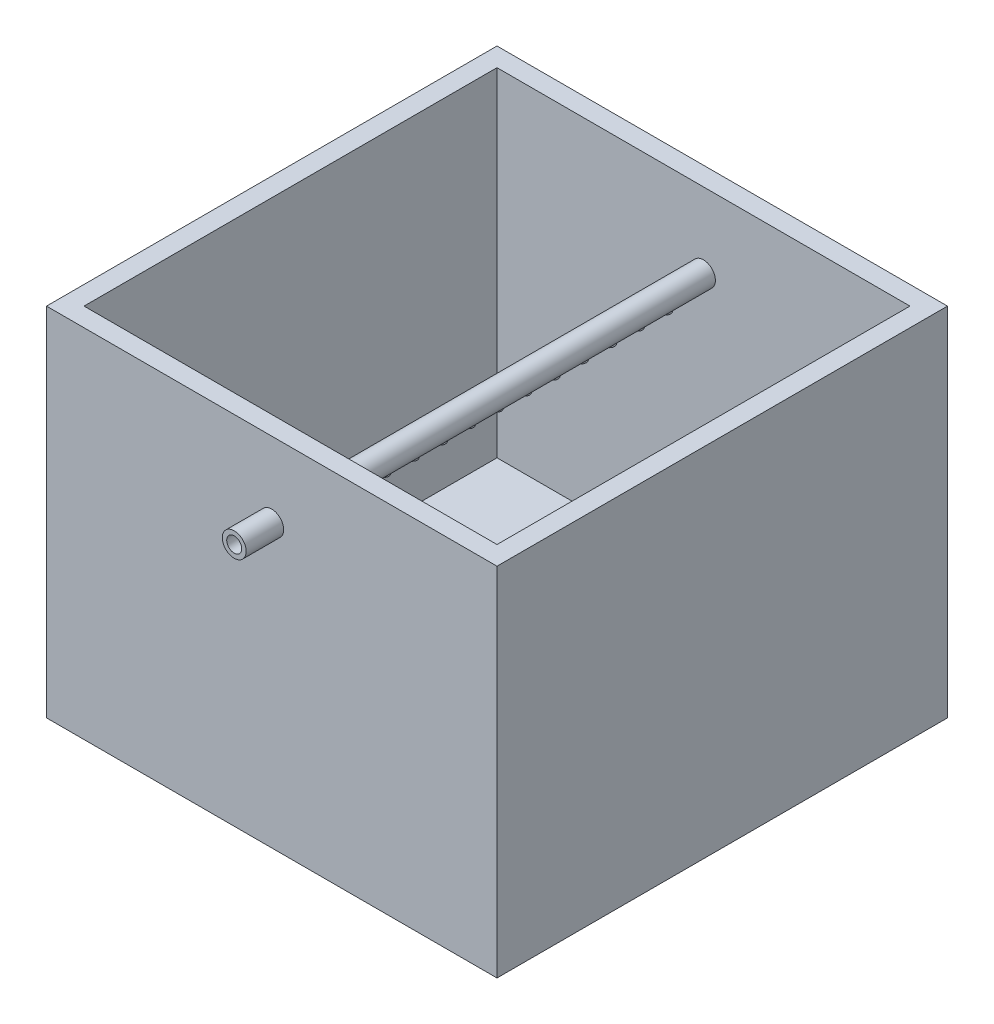
from build123d import *

# Parameters (mm, degrees)
SKETCH1_W                = 120
SKETCH1_H                = 120
BOSS_EXTRUDE1_DEPTH      = 150
SHELL1_T                 = -5
SKETCH2_R                = 3.175
SKETCH2_R_2              = 2
BOSS_EXTRUDE2_DEPTH      = 10
BOSS_EXTRUDE2_DEPTH_BACK = 116
SKETCH3_R                = 1
CUT_EXTRUDE1_DEPTH       = 70
SKETCH4_W                = 120
SKETCH4_H                = 67.243067728
CUT_EXTRUDE2_DEPTH       = 120
SKETCH5_R                = 3.175
SKETCH5_R_2              = 2
BOSS_EXTRUDE3_DEPTH      = 10
SKETCH6_R                = 2
CUT_EXTRUDE3_DEPTH       = 10
SKETCH7_R                = 2
CUT_EXTRUDE4_DEPTH       = 29
SKETCH10_R               = 1.274958532
SKETCH10_R_2             = 1
SKETCH10_R_3             = 1.234995547
SKETCH10_R_4             = 1.322689939
SKETCH10_R_5             = 1.286317059
SKETCH10_R_6             = 1.294952296
SKETCH10_R_7             = 1.196319739
SKETCH10_R_8             = 1.153199308
SKETCH10_R_9             = 1.2271988
SKETCH10_R_10            = 1.254103204
SKETCH10_R_11            = 1.23593489
SKETCH10_R_12            = 1.183992993
SKETCH10_R_13            = 1.194935368
SKETCH10_R_14            = 1.244247118
BOSS_EXTRUDE4_DEPTH      = 0.5
BOSS_EXTRUDE4_DEPTH_BACK = 1


with BuildPart() as part:
    # Sketch1 → Boss-Extrude1 (new body)
    with BuildSketch(Plane(origin=(0, 0, 0), x_dir=(1, 0, 0), z_dir=(0, 1, 0))):
        Rectangle(SKETCH1_W, SKETCH1_H)
    extrude(amount=BOSS_EXTRUDE1_DEPTH)

    # Shell1
    shell1_openings = [part.faces().sort_by_distance(p)[0] for p in [
        (0, 150, 0),
    ]]
    offset(amount=SHELL1_T, openings=shell1_openings, kind=Kind.INTERSECTION)

    # Sketch2 → Boss-Extrude2 (add, two sides)
    with BuildSketch(Plane.XY.offset(60)) as boss_extrude2_sk:
        with Locations((0, 75)):
            Circle(SKETCH2_R)
        with Locations((0, 75)):
            Circle(SKETCH2_R_2, mode=Mode.SUBTRACT)
    extrude(amount=BOSS_EXTRUDE2_DEPTH)
    extrude(boss_extrude2_sk.sketch, amount=-BOSS_EXTRUDE2_DEPTH_BACK)

    # Sketch3 → Cut-Extrude1 (cut)
    with BuildSketch(Plane(origin=(0, 5, 0), x_dir=(1, 0, 0), z_dir=(0, 1, 0))):
        Circle(SKETCH3_R)
        with Locations((0, 7.5)):
            Circle(SKETCH3_R)
        with Locations((0, -7.5)):
            Circle(SKETCH3_R)
        with Locations((0, -15)):
            Circle(SKETCH3_R)
        with Locations((0, 15)):
            Circle(SKETCH3_R)
        with Locations((0, -22.5)):
            Circle(SKETCH3_R)
        with Locations((0, 22.5)):
            Circle(SKETCH3_R)
        with Locations((0, -30)):
            Circle(SKETCH3_R)
        with Locations((0, 30)):
            Circle(SKETCH3_R)
        with Locations((0, -37.5)):
            Circle(SKETCH3_R)
        with Locations((0, 37.5)):
            Circle(SKETCH3_R)
        with Locations((0, -45)):
            Circle(SKETCH3_R)
        with Locations((0, 45)):
            Circle(SKETCH3_R)
    extrude(amount=CUT_EXTRUDE1_DEPTH, mode=Mode.SUBTRACT)

    # Sketch4 → Cut-Extrude2 (cut)
    with BuildSketch(Plane.XY.offset(60)):
        with Locations((0, 128.621533864)):
            Rectangle(SKETCH4_W, SKETCH4_H)
    extrude(amount=-CUT_EXTRUDE2_DEPTH, mode=Mode.SUBTRACT)

    # Sketch5 → Boss-Extrude3 (add)
    with BuildSketch(Plane.ZY.offset(60)):
        with Locations((0, 27.5)):
            Circle(SKETCH5_R)
        with Locations((0, 27.5)):
            Circle(SKETCH5_R_2, mode=Mode.SUBTRACT)
    extrude(amount=BOSS_EXTRUDE3_DEPTH)

    # Sketch6 → Cut-Extrude3 (cut)
    with BuildSketch(Plane.ZY.offset(60)):
        with Locations((0, 27.5)):
            Circle(SKETCH6_R)
    extrude(amount=-CUT_EXTRUDE3_DEPTH, mode=Mode.SUBTRACT)

    # Sketch7 → Cut-Extrude4 (cut)
    with BuildSketch(Plane.XY.offset(70)):
        with Locations((0, 75)):
            Circle(SKETCH7_R)
    extrude(amount=-CUT_EXTRUDE4_DEPTH, mode=Mode.SUBTRACT)

    # Sketch10 → Boss-Extrude4 (add, two sides)
    with BuildSketch(Plane(origin=(0, 71.825, 0), x_dir=(-1, 0, 0), z_dir=(0, -1, 0))) as boss_extrude4_sk:
        with Locations((0, 45)):
            Circle(SKETCH10_R)
        with Locations((0, 45)):
            Circle(SKETCH10_R_2, mode=Mode.SUBTRACT)
        with Locations((0, 37.5)):
            Circle(SKETCH10_R_3)
        with Locations((0, 37.5)):
            Circle(SKETCH10_R_2, mode=Mode.SUBTRACT)
        with Locations((0, 30)):
            Circle(SKETCH10_R_4)
        with Locations((0, 30)):
            Circle(SKETCH10_R_2, mode=Mode.SUBTRACT)
        with Locations((0, 22.5)):
            Circle(SKETCH10_R_5)
        with Locations((0, 22.5)):
            Circle(SKETCH10_R_2, mode=Mode.SUBTRACT)
        with Locations((0, 15)):
            Circle(SKETCH10_R_6)
        with Locations((0, 15)):
            Circle(SKETCH10_R_2, mode=Mode.SUBTRACT)
        with Locations((0, 7.5)):
            Circle(SKETCH10_R_7)
        with Locations((0, 7.5)):
            Circle(SKETCH10_R_2, mode=Mode.SUBTRACT)
        Circle(SKETCH10_R_8)
        Circle(SKETCH10_R_2, mode=Mode.SUBTRACT)
        with Locations((0, -7.5)):
            Circle(SKETCH10_R_9)
        with Locations((0, -7.5)):
            Circle(SKETCH10_R_2, mode=Mode.SUBTRACT)
        with Locations((0, -15)):
            Circle(SKETCH10_R_10)
        with Locations((0, -15)):
            Circle(SKETCH10_R_2, mode=Mode.SUBTRACT)
        with Locations((0, -22.5)):
            Circle(SKETCH10_R_11)
        with Locations((0, -22.5)):
            Circle(SKETCH10_R_2, mode=Mode.SUBTRACT)
        with Locations((0, -30)):
            Circle(SKETCH10_R_12)
        with Locations((0, -30)):
            Circle(SKETCH10_R_2, mode=Mode.SUBTRACT)
        with Locations((0, -37.5)):
            Circle(SKETCH10_R_13)
        with Locations((0, -37.5)):
            Circle(SKETCH10_R_2, mode=Mode.SUBTRACT)
        with Locations((0, -45)):
            Circle(SKETCH10_R_14)
        with Locations((0, -45)):
            Circle(SKETCH10_R_2, mode=Mode.SUBTRACT)
    extrude(amount=BOSS_EXTRUDE4_DEPTH)
    extrude(boss_extrude4_sk.sketch, amount=-BOSS_EXTRUDE4_DEPTH_BACK)


solid = part.part
